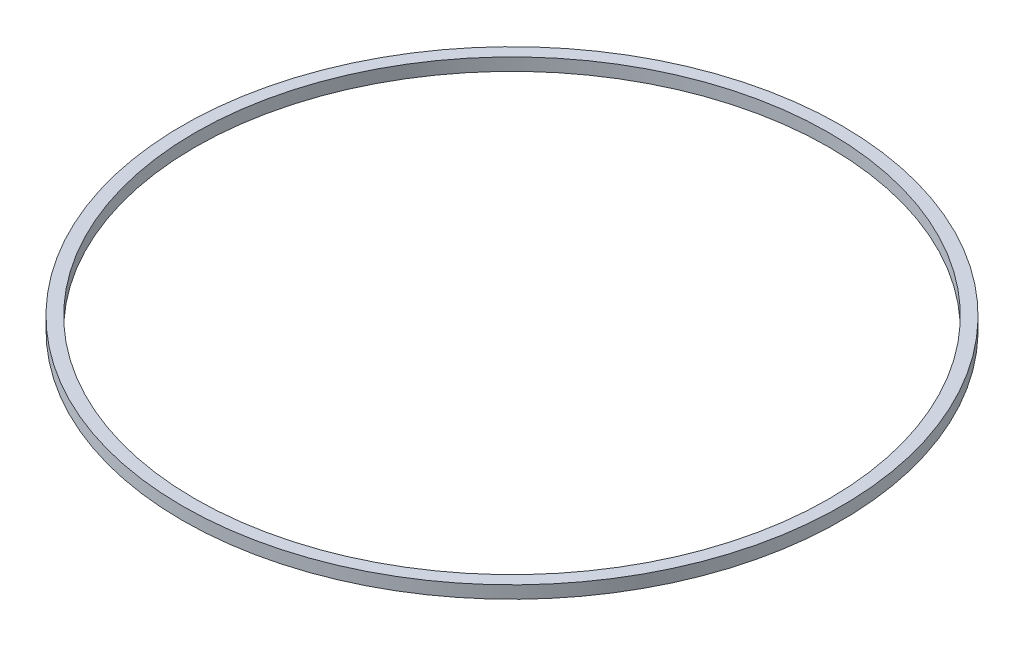
from build123d import *

# Parameters (mm, degrees)
SKETCH1_R           = 79
SKETCH1_R_2         = 76
BOSS_EXTRUDE1_DEPTH = 3


with BuildPart() as part:
    # Sketch1 → Boss-Extrude1 (new body)
    with BuildSketch(Plane(origin=(0, 0, 0), x_dir=(1, 0, 0), z_dir=(0, 1, 0))):
        Circle(SKETCH1_R)
        Circle(SKETCH1_R_2, mode=Mode.SUBTRACT)
    extrude(amount=BOSS_EXTRUDE1_DEPTH)


solid = part.part
